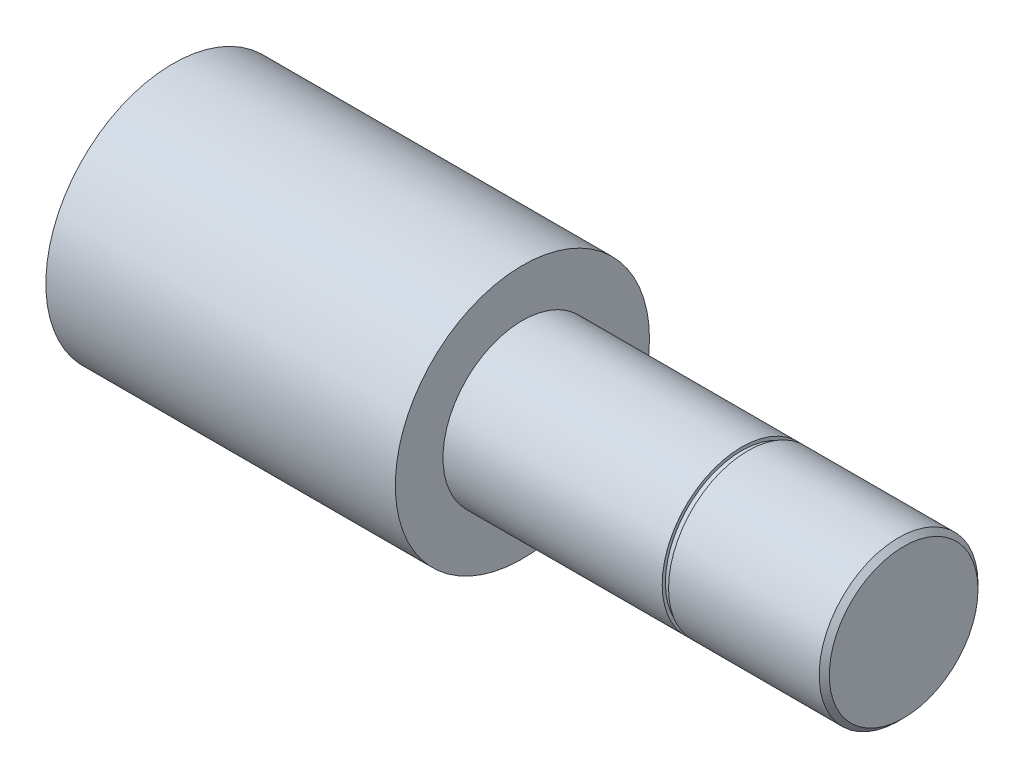
from build123d import *

# Parameters (mm, degrees)
SKIZZE2_W = 1
SKIZZE2_H = 0.5


with BuildPart() as part:
    # Skizze1 → Rotation1 (revolve)
    with BuildSketch(Plane.XY):
        Polygon((0, 20), (0, 0), (115, 0), (115, 11.7), (114.2, 12.5), (55, 12.5), (55, 20), align=None)
    revolve(axis=Axis((0, 0, 0), (1, 0, 0)))

    # Skizze2 → Schnitt-Rotation1 (revolve, cut)
    with BuildSketch(Plane.XY):
        with Locations((90, 12.25)):
            Rectangle(SKIZZE2_W, SKIZZE2_H)
    revolve(axis=Axis((79.835349202, 0, 0), (1, 0, 0)), mode=Mode.SUBTRACT)


solid = part.part
